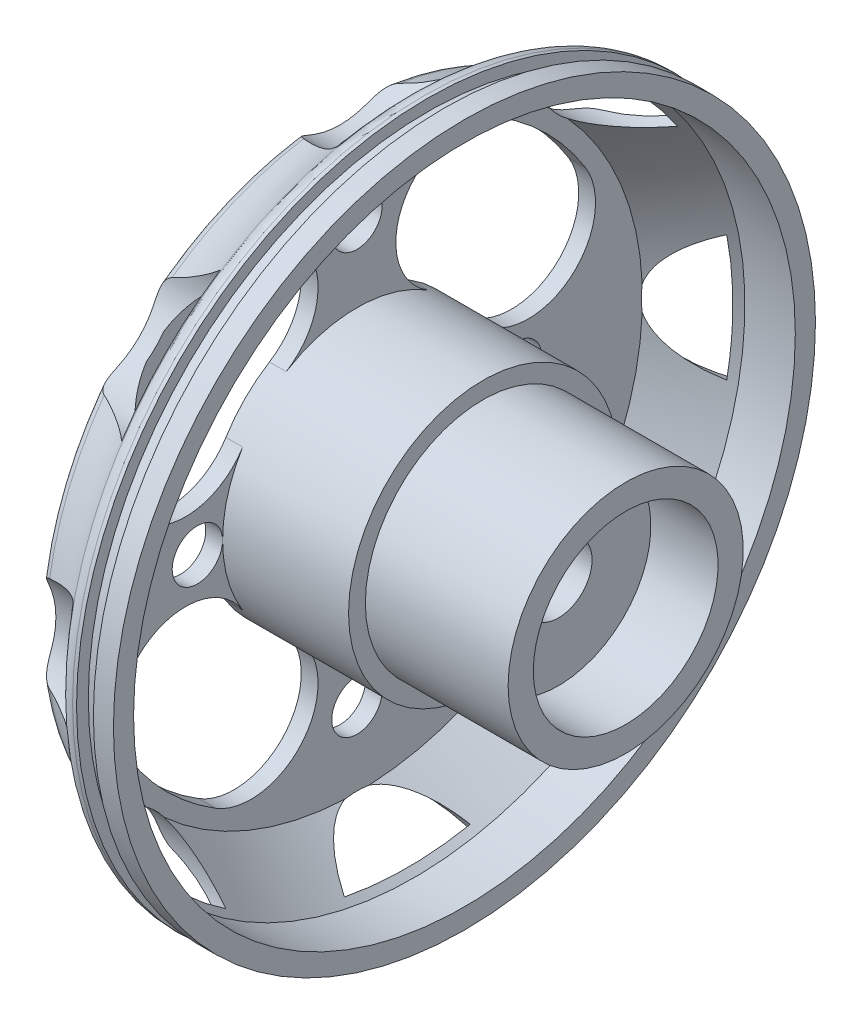
from build123d import *

# Parameters (mm, degrees)
FILLET1_R          = 10
FILLET2_R          = 10
CUT_EXTRUDE2_DEPTH = 40
SKETCH7_R          = 15
CUT_EXTRUDE3_DEPTH = 40


with BuildPart() as part:
    # Sketch1 → Revolve1 (revolve)
    with BuildSketch(Plane.XY):
        with BuildLine():
            Line((170, 55), (130, 55))
            Line((130, 55), (130, 20))
            Line((130, 20), (40, 20))
            Line((40, 20), (40, 55))
            Line((40, 55), (0, 55))
            Line((0, 55), (0, 87.780082712))
            Line((0, 87.780082712), (0, 180))
            ThreePointArc((0, 180), (24.919867603, 190.74503303), (45, 209))
            Line((45, 209), (52.039101444, 209))
            Line((52.039101444, 209), (52.039101444, 201.989107869))
            Line((52.039101444, 201.989107869), (62.070613769, 201.989107869))
            Line((62.070613769, 201.989107869), (62.070613769, 209))
            Line((62.070613769, 209), (74, 209))
            Line((74, 209), (74, 197))
            Line((74, 197), (44, 197))
            Line((44, 197), (10, 170))
            Line((10, 170), (10, 80))
            Line((10, 80), (85, 80))
            Line((85, 80), (85, 70))
            Line((85, 70), (170, 70))
            Line((170, 70), (170, 55))
        make_face()
    revolve(axis=Axis((0, 0, 0), (1, 0, 0)))

    # Fillet1
    fillet1_edges = [part.edges().sort_by_distance(p)[0] for p in [
        (0, -180, 0),
    ]]
    fillet(fillet1_edges, radius=FILLET1_R)

    # Fillet2
    fillet2_edges = [part.edges().sort_by_distance(p)[0] for p in [
        (45, -209, 0),
    ]]
    fillet(fillet2_edges, radius=FILLET2_R)

    # Sketch5 → Cut-Extrude2 (cut)
    with BuildSketch(Plane.ZY):
        with BuildLine():
            ThreePointArc((136.053438888, 84.198941601), (113.13708499, 113.13708499), (84.198941601, 136.053438888))
            ThreePointArc((84.198941601, 136.053438888), (29.135846479, 123.089814566), (42.099470801, 68.026719444))
            ThreePointArc((42.099470801, 68.026719444), (56.568542495, 56.568542495), (68.026719444, 42.099470801))
            ThreePointArc((68.026719444, 42.099470801), (123.089814566, 29.135846479), (136.053438888, 84.198941601))
        make_face()
        with BuildLine():
            ThreePointArc((42.099470801, -68.026719444), (56.568542495, -56.568542495), (68.026719444, -42.099470801))
            ThreePointArc((68.026719444, -42.099470801), (123.089814566, -29.135846479), (136.053438888, -84.198941601))
            ThreePointArc((136.053438888, -84.198941601), (113.13708499, -113.13708499), (84.198941601, -136.053438888))
            ThreePointArc((84.198941601, -136.053438888), (29.135846479, -123.089814566), (42.099470801, -68.026719444))
        make_face()
        with BuildLine():
            ThreePointArc((-68.026719444, -42.099470801), (-56.568542495, -56.568542495), (-42.099470801, -68.026719444))
            ThreePointArc((-42.099470801, -68.026719444), (-29.135846479, -123.089814566), (-84.198941601, -136.053438888))
            ThreePointArc((-84.198941601, -136.053438888), (-113.13708499, -113.13708499), (-136.053438888, -84.198941601))
            ThreePointArc((-136.053438888, -84.198941601), (-123.089814566, -29.135846479), (-68.026719444, -42.099470801))
        make_face()
        with BuildLine():
            ThreePointArc((-42.099470801, 68.026719444), (-56.568542495, 56.568542495), (-68.026719444, 42.099470801))
            ThreePointArc((-68.026719444, 42.099470801), (-123.089814566, 29.135846479), (-136.053438888, 84.198941601))
            ThreePointArc((-136.053438888, 84.198941601), (-113.13708499, 113.13708499), (-84.198941601, 136.053438888))
            ThreePointArc((-84.198941601, 136.053438888), (-29.135846479, 123.089814566), (-42.099470801, 68.026719444))
        make_face()
        with BuildLine():
            ThreePointArc((114.09614791, 175.108734882), (119.668189205, 119.668189205), (175.108734882, 114.09614791))
            ThreePointArc((175.108734882, 114.09614791), (147.785317268, 147.785317268), (114.09614791, 175.108734882))
        make_face()
        with BuildLine():
            ThreePointArc((204.498733775, 43.142413985), (209, 0), (204.498733775, -43.142413985))
            ThreePointArc((204.498733775, -43.142413985), (169.236376159, 0), (204.498733775, 43.142413985))
        make_face()
        with BuildLine():
            ThreePointArc((175.108734882, -114.09614791), (147.785317268, -147.785317268), (114.09614791, -175.108734882))
            ThreePointArc((114.09614791, -175.108734882), (119.668189205, -119.668189205), (175.108734882, -114.09614791))
        make_face()
        with BuildLine():
            ThreePointArc((43.142413985, -204.498733775), (0, -209), (-43.142413985, -204.498733775))
            ThreePointArc((-43.142413985, -204.498733775), (0, -169.236376159), (43.142413985, -204.498733775))
        make_face()
        with BuildLine():
            ThreePointArc((-114.09614791, -175.108734882), (-147.785317268, -147.785317268), (-175.108734882, -114.09614791))
            ThreePointArc((-175.108734882, -114.09614791), (-119.668189205, -119.668189205), (-114.09614791, -175.108734882))
        make_face()
        with BuildLine():
            ThreePointArc((-204.498733775, -43.142413985), (-209, 0), (-204.498733775, 43.142413985))
            ThreePointArc((-204.498733775, 43.142413985), (-169.236376159, 0), (-204.498733775, -43.142413985))
        make_face()
        with BuildLine():
            ThreePointArc((-175.108734882, 114.09614791), (-147.785317268, 147.785317268), (-114.09614791, 175.108734882))
            ThreePointArc((-114.09614791, 175.108734882), (-119.668189205, 119.668189205), (-175.108734882, 114.09614791))
        make_face()
        with BuildLine():
            ThreePointArc((-43.142413985, 204.498733775), (0, 209), (43.142413985, 204.498733775))
            ThreePointArc((43.142413985, 204.498733775), (0, 169.236376159), (-43.142413985, 204.498733775))
        make_face()
    extrude(amount=-CUT_EXTRUDE2_DEPTH, mode=Mode.SUBTRACT)

    # Sketch7 → Cut-Extrude3 (cut)
    with BuildSketch(Plane.ZY):
        with Locations((0, 125)):
            Circle(SKETCH7_R)
        with Locations((0, -125)):
            Circle(SKETCH7_R)
        with Locations((95, 0)):
            Circle(SKETCH7_R)
        with Locations((-95, 0)):
            Circle(SKETCH7_R)
    extrude(amount=-CUT_EXTRUDE3_DEPTH, mode=Mode.SUBTRACT)


solid = part.part
